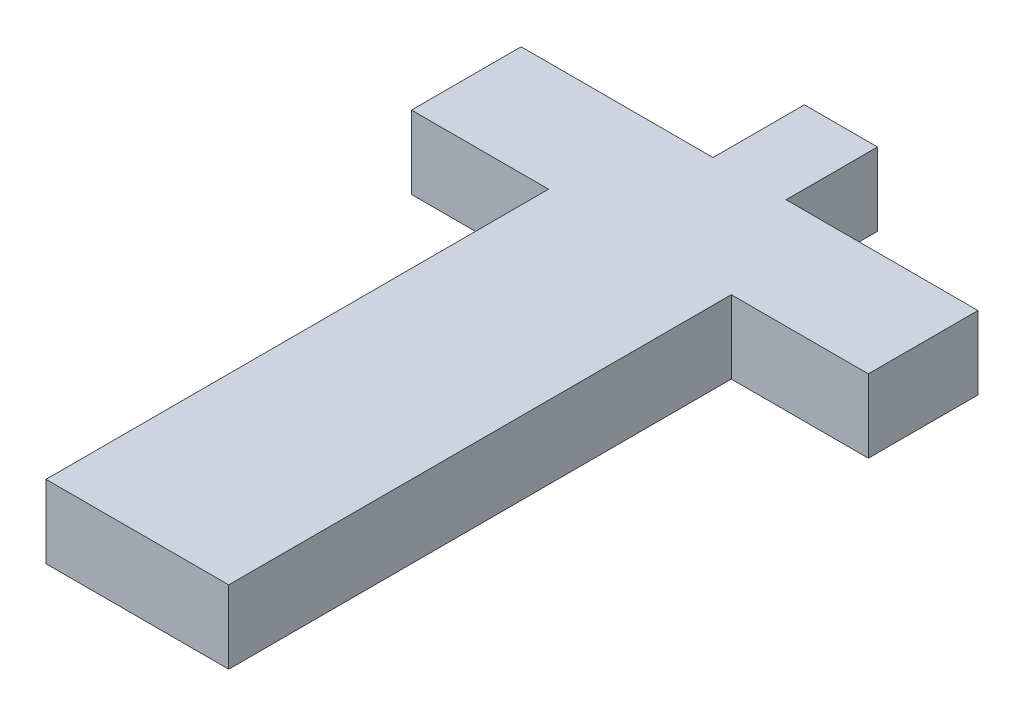
from build123d import *

# Parameters (mm, degrees)
SKETCH_1_W      = 20
SKETCH_1_H      = 8
EXTRUDE_1_DEPTH = 12
SKETCH_5_W      = 8
SKETCH_5_H      = 8
EXTRUDE_5_DEPTH = 10
SKETCH_8_W      = 20
SKETCH_8_H      = 8
EXTRUDE_6_DEPTH = 55
SKETCH_9_W      = 12
SKETCH_9_H      = 8
EXTRUDE_7_DEPTH = 15
SKETCH_10_W     = 12
SKETCH_10_H     = 8
EXTRUDE_8_DEPTH = 15


with BuildPart() as part:
    # ｽｹｯﾁ1 → ﾎﾞｽ - 押し出し1 (new body)
    with BuildSketch(Plane.XY):
        Rectangle(SKETCH_1_W, SKETCH_1_H)
    extrude(amount=EXTRUDE_1_DEPTH)

    # ｽｹｯﾁ5 → ﾎﾞｽ - 押し出し5 (add)
    with BuildSketch(Plane(origin=(0, 0, 0), x_dir=(-1, 0, 0), z_dir=(0, 0, -1))):
        Rectangle(SKETCH_5_W, SKETCH_5_H)
    extrude(amount=EXTRUDE_5_DEPTH)

    # ｽｹｯﾁ8 → ﾎﾞｽ - 押し出し6 (add)
    with BuildSketch(Plane.XY.offset(12)):
        Rectangle(SKETCH_8_W, SKETCH_8_H)
    extrude(amount=EXTRUDE_6_DEPTH)

    # ｽｹｯﾁ9 → ﾎﾞｽ - 押し出し7 (add)
    with BuildSketch(Plane(origin=(10, 0, 0), x_dir=(0, 0, -1), z_dir=(1, 0, 0))):
        with Locations((-6, 0)):
            Rectangle(SKETCH_9_W, SKETCH_9_H)
    extrude(amount=EXTRUDE_7_DEPTH)

    # ｽｹｯﾁ10 → ﾎﾞｽ - 押し出し8 (add)
    with BuildSketch(Plane.ZY.offset(10)):
        with Locations((6, 0)):
            Rectangle(SKETCH_10_W, SKETCH_10_H)
    extrude(amount=EXTRUDE_8_DEPTH)


solid = part.part
